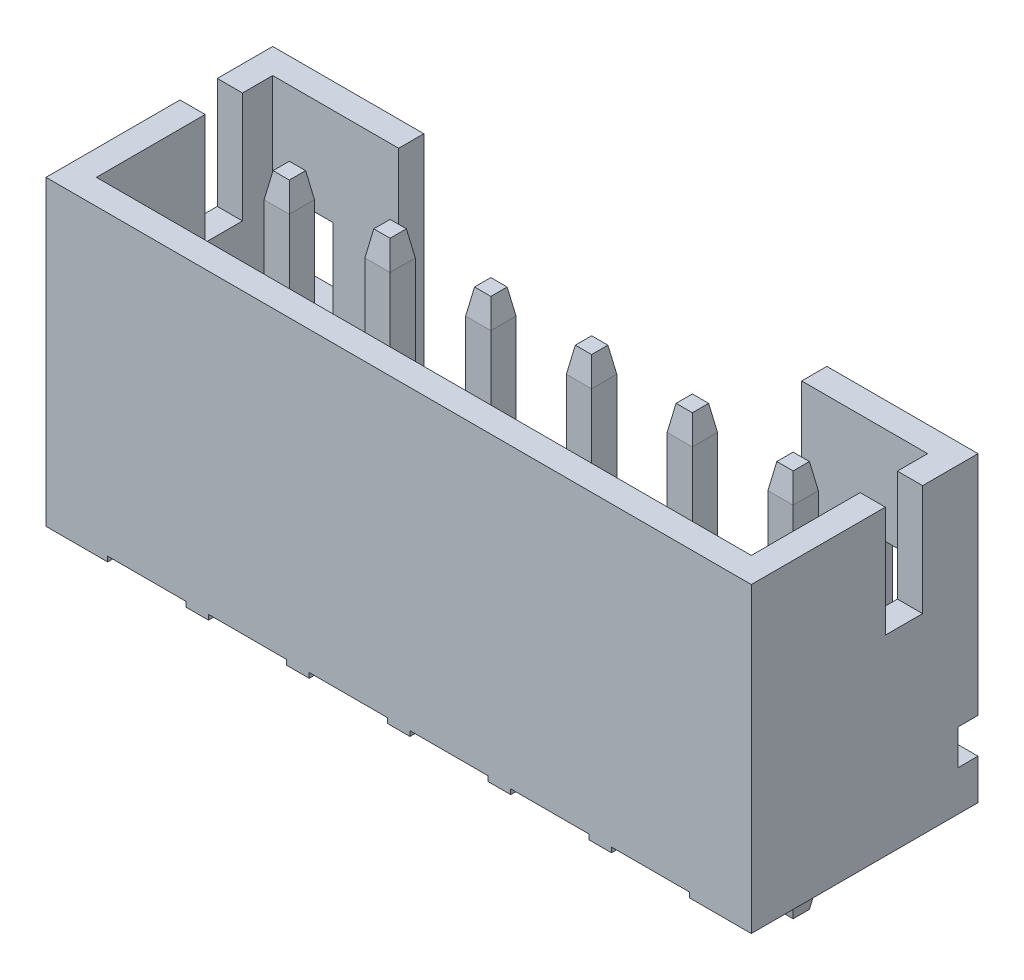
from build123d import *

# Parameters (mm, degrees)
SKETCH1_W               = 14
SKETCH1_H               = 4.5
EXTRUDE1_DEPTH          = 6
CUT_EXTRUDE1_DEPTH      = 5.5
SKETCH3_W               = 13
SKETCH3_H               = 3.5
CUT_EXTRUDE2_DEPTH      = 4.2
SKETCH5_W               = 0.74
SKETCH5_H               = 2.2
CUT_EXTRUDE3_DEPTH      = 15
SKETCH6_W               = 8
SKETCH6_H               = 4
CUT_EXTRUDE4_DEPTH      = 1.2
SKETCH9_W               = 0.4
SKETCH9_H               = 0.7
CUT_EXTRUDE5_DEPTH      = 7
CUT_EXTRUDE5_DEPTH_BACK = 9
SKETCH10_W              = 1.2
SKETCH10_H              = 1.6
CUT_EXTRUDE6_DEPTH      = 0.5
CUT_EXTRUDE7_START      = -7.5
CUT_EXTRUDE7_DEPTH      = 13
LPATTERN4_COUNT         = 3
LPATTERN4_PITCH         = 2
LPATTERN4_COL_COUNT     = 4
LPATTERN4_COL_PITCH     = 2
EXTRUDE2_START          = -2
EXTRUDE2_DEPTH          = 7.7
LPATTERN2_COUNT         = 3
LPATTERN2_PITCH         = 2
LPATTERN2_COL_COUNT     = 4
LPATTERN2_COL_PITCH     = 2
CHAMFER1_SIZE           = 0.5
CHAMFER1_SIZE2          = 0.08816349
CHAMFER1_PART_2_SIZE    = 0.5
CHAMFER1_PART_2_SIZE2   = 0.08816349
CHAMFER1_PART_3_SIZE    = 0.5
CHAMFER1_PART_3_SIZE2   = 0.08816349
CHAMFER1_PART_4_SIZE    = 0.5
CHAMFER1_PART_4_SIZE2   = 0.08816349
CHAMFER1_PART_5_SIZE    = 0.5
CHAMFER1_PART_5_SIZE2   = 0.08816349
CHAMFER1_PART_6_SIZE    = 0.5
CHAMFER1_PART_6_SIZE2   = 0.08816349
CHAMFER1_PART_7_SIZE    = 0.5
CHAMFER1_PART_7_SIZE2   = 0.08816349
CHAMFER1_PART_8_SIZE    = 0.5
CHAMFER1_PART_8_SIZE2   = 0.08816349
CHAMFER1_PART_9_SIZE    = 0.5
CHAMFER1_PART_9_SIZE2   = 0.08816349
CHAMFER1_PART_10_SIZE   = 0.5
CHAMFER1_PART_10_SIZE2  = 0.08816349
CHAMFER1_PART_11_SIZE   = 0.5
CHAMFER1_PART_11_SIZE2  = 0.08816349
CHAMFER1_PART_12_SIZE   = 0.5
CHAMFER1_PART_12_SIZE2  = 0.08816349
CHAMFER1_PART_13_SIZE   = 0.5
CHAMFER1_PART_13_SIZE2  = 0.08816349
CHAMFER1_PART_14_SIZE   = 0.5
CHAMFER1_PART_14_SIZE2  = 0.08816349
CHAMFER1_PART_15_SIZE   = 0.5
CHAMFER1_PART_15_SIZE2  = 0.08816349
CHAMFER1_PART_16_SIZE   = 0.5
CHAMFER1_PART_16_SIZE2  = 0.08816349
CHAMFER1_PART_17_SIZE   = 0.5
CHAMFER1_PART_17_SIZE2  = 0.08816349
CHAMFER1_PART_18_SIZE   = 0.5
CHAMFER1_PART_18_SIZE2  = 0.08816349
CHAMFER1_PART_19_SIZE   = 0.5
CHAMFER1_PART_19_SIZE2  = 0.08816349
CHAMFER1_PART_20_SIZE   = 0.5
CHAMFER1_PART_20_SIZE2  = 0.08816349
CHAMFER1_PART_21_SIZE   = 0.5
CHAMFER1_PART_21_SIZE2  = 0.08816349
CHAMFER1_PART_22_SIZE   = 0.5
CHAMFER1_PART_22_SIZE2  = 0.08816349
CHAMFER1_PART_23_SIZE   = 0.5
CHAMFER1_PART_23_SIZE2  = 0.08816349
CHAMFER1_PART_24_SIZE   = 0.5
CHAMFER1_PART_24_SIZE2  = 0.08816349
CHAMFER1_PART_25_SIZE   = 0.5
CHAMFER1_PART_25_SIZE2  = 0.08816349
CHAMFER1_PART_26_SIZE   = 0.5
CHAMFER1_PART_26_SIZE2  = 0.08816349
CHAMFER1_PART_27_SIZE   = 0.5
CHAMFER1_PART_27_SIZE2  = 0.08816349
CHAMFER1_PART_28_SIZE   = 0.5
CHAMFER1_PART_28_SIZE2  = 0.08816349
CHAMFER1_PART_29_SIZE   = 0.5
CHAMFER1_PART_29_SIZE2  = 0.08816349
CHAMFER1_PART_30_SIZE   = 0.5
CHAMFER1_PART_30_SIZE2  = 0.08816349
CHAMFER1_PART_31_SIZE   = 0.5
CHAMFER1_PART_31_SIZE2  = 0.08816349
CHAMFER1_PART_32_SIZE   = 0.5
CHAMFER1_PART_32_SIZE2  = 0.08816349
CHAMFER1_PART_33_SIZE   = 0.5
CHAMFER1_PART_33_SIZE2  = 0.08816349
CHAMFER1_PART_34_SIZE   = 0.5
CHAMFER1_PART_34_SIZE2  = 0.08816349
CHAMFER1_PART_35_SIZE   = 0.5
CHAMFER1_PART_35_SIZE2  = 0.08816349
CHAMFER1_PART_36_SIZE   = 0.5
CHAMFER1_PART_36_SIZE2  = 0.08816349
CHAMFER1_PART_37_SIZE   = 0.5
CHAMFER1_PART_37_SIZE2  = 0.08816349
CHAMFER1_PART_38_SIZE   = 0.5
CHAMFER1_PART_38_SIZE2  = 0.08816349
CHAMFER1_PART_39_SIZE   = 0.5
CHAMFER1_PART_39_SIZE2  = 0.08816349
CHAMFER1_PART_40_SIZE   = 0.5
CHAMFER1_PART_40_SIZE2  = 0.08816349
CHAMFER1_PART_41_SIZE   = 0.5
CHAMFER1_PART_41_SIZE2  = 0.08816349
CHAMFER1_PART_42_SIZE   = 0.5
CHAMFER1_PART_42_SIZE2  = 0.08816349
CHAMFER1_PART_43_SIZE   = 0.5
CHAMFER1_PART_43_SIZE2  = 0.08816349
CHAMFER1_PART_44_SIZE   = 0.5
CHAMFER1_PART_44_SIZE2  = 0.08816349
CHAMFER1_PART_45_SIZE   = 0.5
CHAMFER1_PART_45_SIZE2  = 0.08816349
CHAMFER1_PART_46_SIZE   = 0.5
CHAMFER1_PART_46_SIZE2  = 0.08816349
CHAMFER1_PART_47_SIZE   = 0.5
CHAMFER1_PART_47_SIZE2  = 0.08816349
CHAMFER1_PART_48_SIZE   = 0.5
CHAMFER1_PART_48_SIZE2  = 0.08816349


with BuildPart() as part:
    # Sketch1 → Extrude1 (new body)
    with BuildSketch(Plane(origin=(0, 0, 0), x_dir=(1, 0, 0), z_dir=(0, 1, 0))):
        with Locations((-1, 0)):
            Rectangle(SKETCH1_W, SKETCH1_H)
    extrude(amount=EXTRUDE1_DEPTH)

    # Sketch2 → Cut-Extrude1 (cut, through all)
    with BuildSketch(Plane.XY.offset(2.25)):
        Polygon((-0.775, 0.1), (0.775, 0.1), (0.775, 0), (0, 0), (-0.775, 0), align=None)
    cut_extrude1 = extrude(amount=-CUT_EXTRUDE1_DEPTH, mode=Mode.SUBTRACT)

    # Sketch3 → Cut-Extrude2 (cut)
    with BuildSketch(Plane(origin=(0, 6, 0), x_dir=(-1, 0, 0), z_dir=(0, 1, 0))):
        with Locations((1, 0)):
            Rectangle(SKETCH3_W, SKETCH3_H)
    extrude(amount=-CUT_EXTRUDE2_DEPTH, mode=Mode.SUBTRACT)

    # Sketch5 → Cut-Extrude3 (cut, through all)
    with BuildSketch(Plane.ZY.offset(8)):
        with Locations((-0.78, 4.9)):
            Rectangle(SKETCH5_W, SKETCH5_H)
    extrude(amount=-CUT_EXTRUDE3_DEPTH, mode=Mode.SUBTRACT)

    # Sketch6 → Cut-Extrude4 (cut)
    with BuildSketch(Plane(origin=(0, 0, -2.25), x_dir=(-1, 0, 0), z_dir=(0, 0, -1))):
        with Locations((1, 4)):
            Rectangle(SKETCH6_W, SKETCH6_H)
    extrude(amount=-CUT_EXTRUDE4_DEPTH, mode=Mode.SUBTRACT)

    # Sketch9 → Cut-Extrude5 (cut, two sides)
    with BuildSketch(Plane(origin=(0, 0, 0), x_dir=(0, 0, -1), z_dir=(1, 0, 0))) as cut_extrude5_sk:
        with Locations((2.05, 1.15)):
            Rectangle(SKETCH9_W, SKETCH9_H)
    extrude(amount=CUT_EXTRUDE5_DEPTH, mode=Mode.SUBTRACT)
    extrude(cut_extrude5_sk.sketch, amount=-CUT_EXTRUDE5_DEPTH_BACK, mode=Mode.SUBTRACT)

    # Sketch10 → Cut-Extrude6 (cut)
    with BuildSketch(Plane(origin=(0, 0, -2.25), x_dir=(-1, 0, 0), z_dir=(0, 0, -1))):
        with Locations((-4.9, 3.271645398)):
            Rectangle(SKETCH10_W, SKETCH10_H)
        with Locations((6.9, 3.271645398)):
            Rectangle(SKETCH10_W, SKETCH10_H)
    extrude(amount=-CUT_EXTRUDE6_DEPTH, mode=Mode.SUBTRACT)

    # Sketch11 → Cut-Extrude7 (cut)
    with BuildSketch(Plane(origin=(0, 0, 0), x_dir=(0, 0, -1), z_dir=(1, 0, 0)).offset(CUT_EXTRUDE7_START)):
        Polygon((0, 1.8), (-0.576387184, 1.223612816), (-1.75, 1.223612816), (-1.75, 1.8), align=None)
    extrude(amount=CUT_EXTRUDE7_DEPTH, mode=Mode.SUBTRACT)

    # LPattern4: Cut-Extrude1 ×3
    with Locations(*[(i * LPATTERN4_PITCH, 0, 0) for i in range(1, LPATTERN4_COUNT)]):
        add(cut_extrude1, mode=Mode.SUBTRACT)

    # LPattern4 col: Cut-Extrude1 ×4
    with Locations(*[(-i * LPATTERN4_COL_PITCH, 0, 0) for i in range(1, LPATTERN4_COL_COUNT)]):
        add(cut_extrude1, mode=Mode.SUBTRACT)

    # Sketch7 → Extrude2 (add)
    with BuildSketch(Plane(origin=(0, 0, 0), x_dir=(1, 0, 0), z_dir=(0, 1, 0)).offset(EXTRUDE2_START)):
        Polygon((0, 0.33), (0.25, 0.33), (0.25, 0.83), (-0.25, 0.83), (-0.25, 0.33), align=None)
    extrude2 = extrude(amount=EXTRUDE2_DEPTH)

    # LPattern2: Extrude2 ×3
    with Locations(*[(i * LPATTERN2_PITCH, 0, 0) for i in range(1, LPATTERN2_COUNT)]):
        add(extrude2)

    # LPattern2 col: Extrude2 ×4
    with Locations(*[(-i * LPATTERN2_COL_PITCH, 0, 0) for i in range(1, LPATTERN2_COL_COUNT)]):
        add(extrude2)

    # Chamfer1
    chamfer1_edges = [part.edges().sort_by_distance(p)[0] for p in [
        (-0.25, -2, -0.58),
    ]]
    chamfer1_side = [part.faces().sort_by_distance(p)[0] for p in [
        (-0.25, -0.95, -0.58),
    ]]
    chamfer(chamfer1_edges, length=CHAMFER1_SIZE, length2=CHAMFER1_SIZE2, reference=chamfer1_side[0])

    # Chamfer1 part 2
    chamfer1_part_2_edges = [part.edges().sort_by_distance(p)[0] for p in [
        (0, -2, -0.33),
    ]]
    chamfer1_part_2_side = [part.faces().sort_by_distance(p)[0] for p in [
        (0, -0.95, -0.33),
    ]]
    chamfer(chamfer1_part_2_edges, length=CHAMFER1_PART_2_SIZE, length2=CHAMFER1_PART_2_SIZE2, reference=chamfer1_part_2_side[0])

    # Chamfer1 part 3
    chamfer1_part_3_edges = [part.edges().sort_by_distance(p)[0] for p in [
        (0.25, -2, -0.58),
    ]]
    chamfer1_part_3_side = [part.faces().sort_by_distance(p)[0] for p in [
        (0.25, -0.95, -0.58),
    ]]
    chamfer(chamfer1_part_3_edges, length=CHAMFER1_PART_3_SIZE, length2=CHAMFER1_PART_3_SIZE2, reference=chamfer1_part_3_side[0])

    # Chamfer1 part 4
    chamfer1_part_4_edges = [part.edges().sort_by_distance(p)[0] for p in [
        (0, -2, -0.83),
    ]]
    chamfer1_part_4_side = [part.faces().sort_by_distance(p)[0] for p in [
        (0, -0.95, -0.83),
    ]]
    chamfer(chamfer1_part_4_edges, length=CHAMFER1_PART_4_SIZE, length2=CHAMFER1_PART_4_SIZE2, reference=chamfer1_part_4_side[0])

    # Chamfer1 part 5
    chamfer1_part_5_edges = [part.edges().sort_by_distance(p)[0] for p in [
        (0, 5.7, -0.83),
    ]]
    chamfer1_part_5_side = [part.faces().sort_by_distance(p)[0] for p in [
        (0, 3.75, -0.83),
    ]]
    chamfer(chamfer1_part_5_edges, length=CHAMFER1_PART_5_SIZE, length2=CHAMFER1_PART_5_SIZE2, reference=chamfer1_part_5_side[0])

    # Chamfer1 part 6
    chamfer1_part_6_edges = [part.edges().sort_by_distance(p)[0] for p in [
        (-0.25, 5.7, -0.58),
    ]]
    chamfer1_part_6_side = [part.faces().sort_by_distance(p)[0] for p in [
        (-0.25, 3.75, -0.58),
    ]]
    chamfer(chamfer1_part_6_edges, length=CHAMFER1_PART_6_SIZE, length2=CHAMFER1_PART_6_SIZE2, reference=chamfer1_part_6_side[0])

    # Chamfer1 part 7
    chamfer1_part_7_edges = [part.edges().sort_by_distance(p)[0] for p in [
        (0, 5.7, -0.33),
    ]]
    chamfer1_part_7_side = [part.faces().sort_by_distance(p)[0] for p in [
        (0, 3.75, -0.33),
    ]]
    chamfer(chamfer1_part_7_edges, length=CHAMFER1_PART_7_SIZE, length2=CHAMFER1_PART_7_SIZE2, reference=chamfer1_part_7_side[0])

    # Chamfer1 part 8
    chamfer1_part_8_edges = [part.edges().sort_by_distance(p)[0] for p in [
        (0.25, 5.7, -0.58),
    ]]
    chamfer1_part_8_side = [part.faces().sort_by_distance(p)[0] for p in [
        (0.25, 3.75, -0.58),
    ]]
    chamfer(chamfer1_part_8_edges, length=CHAMFER1_PART_8_SIZE, length2=CHAMFER1_PART_8_SIZE2, reference=chamfer1_part_8_side[0])

    # Chamfer1 part 9
    chamfer1_part_9_edges = [part.edges().sort_by_distance(p)[0] for p in [
        (-2.25, -2, -0.58),
    ]]
    chamfer1_part_9_side = [part.faces().sort_by_distance(p)[0] for p in [
        (-2.25, -0.95, -0.58),
    ]]
    chamfer(chamfer1_part_9_edges, length=CHAMFER1_PART_9_SIZE, length2=CHAMFER1_PART_9_SIZE2, reference=chamfer1_part_9_side[0])

    # Chamfer1 part 10
    chamfer1_part_10_edges = [part.edges().sort_by_distance(p)[0] for p in [
        (-2, -2, -0.33),
    ]]
    chamfer1_part_10_side = [part.faces().sort_by_distance(p)[0] for p in [
        (-2, -0.95, -0.33),
    ]]
    chamfer(chamfer1_part_10_edges, length=CHAMFER1_PART_10_SIZE, length2=CHAMFER1_PART_10_SIZE2, reference=chamfer1_part_10_side[0])

    # Chamfer1 part 11
    chamfer1_part_11_edges = [part.edges().sort_by_distance(p)[0] for p in [
        (-1.75, -2, -0.58),
    ]]
    chamfer1_part_11_side = [part.faces().sort_by_distance(p)[0] for p in [
        (-1.75, -0.95, -0.58),
    ]]
    chamfer(chamfer1_part_11_edges, length=CHAMFER1_PART_11_SIZE, length2=CHAMFER1_PART_11_SIZE2, reference=chamfer1_part_11_side[0])

    # Chamfer1 part 12
    chamfer1_part_12_edges = [part.edges().sort_by_distance(p)[0] for p in [
        (-2, -2, -0.83),
    ]]
    chamfer1_part_12_side = [part.faces().sort_by_distance(p)[0] for p in [
        (-2, -0.95, -0.83),
    ]]
    chamfer(chamfer1_part_12_edges, length=CHAMFER1_PART_12_SIZE, length2=CHAMFER1_PART_12_SIZE2, reference=chamfer1_part_12_side[0])

    # Chamfer1 part 13
    chamfer1_part_13_edges = [part.edges().sort_by_distance(p)[0] for p in [
        (-2, 5.7, -0.83),
    ]]
    chamfer1_part_13_side = [part.faces().sort_by_distance(p)[0] for p in [
        (-2, 3.75, -0.83),
    ]]
    chamfer(chamfer1_part_13_edges, length=CHAMFER1_PART_13_SIZE, length2=CHAMFER1_PART_13_SIZE2, reference=chamfer1_part_13_side[0])

    # Chamfer1 part 14
    chamfer1_part_14_edges = [part.edges().sort_by_distance(p)[0] for p in [
        (-2.25, 5.7, -0.58),
    ]]
    chamfer1_part_14_side = [part.faces().sort_by_distance(p)[0] for p in [
        (-2.25, 3.75, -0.58),
    ]]
    chamfer(chamfer1_part_14_edges, length=CHAMFER1_PART_14_SIZE, length2=CHAMFER1_PART_14_SIZE2, reference=chamfer1_part_14_side[0])

    # Chamfer1 part 15
    chamfer1_part_15_edges = [part.edges().sort_by_distance(p)[0] for p in [
        (-2, 5.7, -0.33),
    ]]
    chamfer1_part_15_side = [part.faces().sort_by_distance(p)[0] for p in [
        (-2, 3.75, -0.33),
    ]]
    chamfer(chamfer1_part_15_edges, length=CHAMFER1_PART_15_SIZE, length2=CHAMFER1_PART_15_SIZE2, reference=chamfer1_part_15_side[0])

    # Chamfer1 part 16
    chamfer1_part_16_edges = [part.edges().sort_by_distance(p)[0] for p in [
        (-1.75, 5.7, -0.58),
    ]]
    chamfer1_part_16_side = [part.faces().sort_by_distance(p)[0] for p in [
        (-1.75, 3.75, -0.58),
    ]]
    chamfer(chamfer1_part_16_edges, length=CHAMFER1_PART_16_SIZE, length2=CHAMFER1_PART_16_SIZE2, reference=chamfer1_part_16_side[0])

    # Chamfer1 part 17
    chamfer1_part_17_edges = [part.edges().sort_by_distance(p)[0] for p in [
        (-4.25, -2, -0.58),
    ]]
    chamfer1_part_17_side = [part.faces().sort_by_distance(p)[0] for p in [
        (-4.25, -0.95, -0.58),
    ]]
    chamfer(chamfer1_part_17_edges, length=CHAMFER1_PART_17_SIZE, length2=CHAMFER1_PART_17_SIZE2, reference=chamfer1_part_17_side[0])

    # Chamfer1 part 18
    chamfer1_part_18_edges = [part.edges().sort_by_distance(p)[0] for p in [
        (-4, -2, -0.33),
    ]]
    chamfer1_part_18_side = [part.faces().sort_by_distance(p)[0] for p in [
        (-4, -0.95, -0.33),
    ]]
    chamfer(chamfer1_part_18_edges, length=CHAMFER1_PART_18_SIZE, length2=CHAMFER1_PART_18_SIZE2, reference=chamfer1_part_18_side[0])

    # Chamfer1 part 19
    chamfer1_part_19_edges = [part.edges().sort_by_distance(p)[0] for p in [
        (-3.75, -2, -0.58),
    ]]
    chamfer1_part_19_side = [part.faces().sort_by_distance(p)[0] for p in [
        (-3.75, -0.95, -0.58),
    ]]
    chamfer(chamfer1_part_19_edges, length=CHAMFER1_PART_19_SIZE, length2=CHAMFER1_PART_19_SIZE2, reference=chamfer1_part_19_side[0])

    # Chamfer1 part 20
    chamfer1_part_20_edges = [part.edges().sort_by_distance(p)[0] for p in [
        (-4, -2, -0.83),
    ]]
    chamfer1_part_20_side = [part.faces().sort_by_distance(p)[0] for p in [
        (-4, -0.95, -0.83),
    ]]
    chamfer(chamfer1_part_20_edges, length=CHAMFER1_PART_20_SIZE, length2=CHAMFER1_PART_20_SIZE2, reference=chamfer1_part_20_side[0])

    # Chamfer1 part 21
    chamfer1_part_21_edges = [part.edges().sort_by_distance(p)[0] for p in [
        (-4, 5.7, -0.83),
    ]]
    chamfer1_part_21_side = [part.faces().sort_by_distance(p)[0] for p in [
        (-4, 3.75, -0.83),
    ]]
    chamfer(chamfer1_part_21_edges, length=CHAMFER1_PART_21_SIZE, length2=CHAMFER1_PART_21_SIZE2, reference=chamfer1_part_21_side[0])

    # Chamfer1 part 22
    chamfer1_part_22_edges = [part.edges().sort_by_distance(p)[0] for p in [
        (-4.25, 5.7, -0.58),
    ]]
    chamfer1_part_22_side = [part.faces().sort_by_distance(p)[0] for p in [
        (-4.25, 3.75, -0.58),
    ]]
    chamfer(chamfer1_part_22_edges, length=CHAMFER1_PART_22_SIZE, length2=CHAMFER1_PART_22_SIZE2, reference=chamfer1_part_22_side[0])

    # Chamfer1 part 23
    chamfer1_part_23_edges = [part.edges().sort_by_distance(p)[0] for p in [
        (-4, 5.7, -0.33),
    ]]
    chamfer1_part_23_side = [part.faces().sort_by_distance(p)[0] for p in [
        (-4, 3.75, -0.33),
    ]]
    chamfer(chamfer1_part_23_edges, length=CHAMFER1_PART_23_SIZE, length2=CHAMFER1_PART_23_SIZE2, reference=chamfer1_part_23_side[0])

    # Chamfer1 part 24
    chamfer1_part_24_edges = [part.edges().sort_by_distance(p)[0] for p in [
        (-3.75, 5.7, -0.58),
    ]]
    chamfer1_part_24_side = [part.faces().sort_by_distance(p)[0] for p in [
        (-3.75, 3.75, -0.58),
    ]]
    chamfer(chamfer1_part_24_edges, length=CHAMFER1_PART_24_SIZE, length2=CHAMFER1_PART_24_SIZE2, reference=chamfer1_part_24_side[0])

    # Chamfer1 part 25
    chamfer1_part_25_edges = [part.edges().sort_by_distance(p)[0] for p in [
        (-6.25, -2, -0.58),
    ]]
    chamfer1_part_25_side = [part.faces().sort_by_distance(p)[0] for p in [
        (-6.25, -0.95, -0.58),
    ]]
    chamfer(chamfer1_part_25_edges, length=CHAMFER1_PART_25_SIZE, length2=CHAMFER1_PART_25_SIZE2, reference=chamfer1_part_25_side[0])

    # Chamfer1 part 26
    chamfer1_part_26_edges = [part.edges().sort_by_distance(p)[0] for p in [
        (-6, -2, -0.33),
    ]]
    chamfer1_part_26_side = [part.faces().sort_by_distance(p)[0] for p in [
        (-6, -0.95, -0.33),
    ]]
    chamfer(chamfer1_part_26_edges, length=CHAMFER1_PART_26_SIZE, length2=CHAMFER1_PART_26_SIZE2, reference=chamfer1_part_26_side[0])

    # Chamfer1 part 27
    chamfer1_part_27_edges = [part.edges().sort_by_distance(p)[0] for p in [
        (-5.75, -2, -0.58),
    ]]
    chamfer1_part_27_side = [part.faces().sort_by_distance(p)[0] for p in [
        (-5.75, -0.95, -0.58),
    ]]
    chamfer(chamfer1_part_27_edges, length=CHAMFER1_PART_27_SIZE, length2=CHAMFER1_PART_27_SIZE2, reference=chamfer1_part_27_side[0])

    # Chamfer1 part 28
    chamfer1_part_28_edges = [part.edges().sort_by_distance(p)[0] for p in [
        (-6, -2, -0.83),
    ]]
    chamfer1_part_28_side = [part.faces().sort_by_distance(p)[0] for p in [
        (-6, -0.95, -0.83),
    ]]
    chamfer(chamfer1_part_28_edges, length=CHAMFER1_PART_28_SIZE, length2=CHAMFER1_PART_28_SIZE2, reference=chamfer1_part_28_side[0])

    # Chamfer1 part 29
    chamfer1_part_29_edges = [part.edges().sort_by_distance(p)[0] for p in [
        (-6, 5.7, -0.83),
    ]]
    chamfer1_part_29_side = [part.faces().sort_by_distance(p)[0] for p in [
        (-6, 3.75, -0.83),
    ]]
    chamfer(chamfer1_part_29_edges, length=CHAMFER1_PART_29_SIZE, length2=CHAMFER1_PART_29_SIZE2, reference=chamfer1_part_29_side[0])

    # Chamfer1 part 30
    chamfer1_part_30_edges = [part.edges().sort_by_distance(p)[0] for p in [
        (-6.25, 5.7, -0.58),
    ]]
    chamfer1_part_30_side = [part.faces().sort_by_distance(p)[0] for p in [
        (-6.25, 3.75, -0.58),
    ]]
    chamfer(chamfer1_part_30_edges, length=CHAMFER1_PART_30_SIZE, length2=CHAMFER1_PART_30_SIZE2, reference=chamfer1_part_30_side[0])

    # Chamfer1 part 31
    chamfer1_part_31_edges = [part.edges().sort_by_distance(p)[0] for p in [
        (-6, 5.7, -0.33),
    ]]
    chamfer1_part_31_side = [part.faces().sort_by_distance(p)[0] for p in [
        (-6, 3.75, -0.33),
    ]]
    chamfer(chamfer1_part_31_edges, length=CHAMFER1_PART_31_SIZE, length2=CHAMFER1_PART_31_SIZE2, reference=chamfer1_part_31_side[0])

    # Chamfer1 part 32
    chamfer1_part_32_edges = [part.edges().sort_by_distance(p)[0] for p in [
        (-5.75, 5.7, -0.58),
    ]]
    chamfer1_part_32_side = [part.faces().sort_by_distance(p)[0] for p in [
        (-5.75, 3.75, -0.58),
    ]]
    chamfer(chamfer1_part_32_edges, length=CHAMFER1_PART_32_SIZE, length2=CHAMFER1_PART_32_SIZE2, reference=chamfer1_part_32_side[0])

    # Chamfer1 part 33
    chamfer1_part_33_edges = [part.edges().sort_by_distance(p)[0] for p in [
        (1.75, -2, -0.58),
    ]]
    chamfer1_part_33_side = [part.faces().sort_by_distance(p)[0] for p in [
        (1.75, -0.95, -0.58),
    ]]
    chamfer(chamfer1_part_33_edges, length=CHAMFER1_PART_33_SIZE, length2=CHAMFER1_PART_33_SIZE2, reference=chamfer1_part_33_side[0])

    # Chamfer1 part 34
    chamfer1_part_34_edges = [part.edges().sort_by_distance(p)[0] for p in [
        (2, -2, -0.33),
    ]]
    chamfer1_part_34_side = [part.faces().sort_by_distance(p)[0] for p in [
        (2, -0.95, -0.33),
    ]]
    chamfer(chamfer1_part_34_edges, length=CHAMFER1_PART_34_SIZE, length2=CHAMFER1_PART_34_SIZE2, reference=chamfer1_part_34_side[0])

    # Chamfer1 part 35
    chamfer1_part_35_edges = [part.edges().sort_by_distance(p)[0] for p in [
        (2.25, -2, -0.58),
    ]]
    chamfer1_part_35_side = [part.faces().sort_by_distance(p)[0] for p in [
        (2.25, -0.95, -0.58),
    ]]
    chamfer(chamfer1_part_35_edges, length=CHAMFER1_PART_35_SIZE, length2=CHAMFER1_PART_35_SIZE2, reference=chamfer1_part_35_side[0])

    # Chamfer1 part 36
    chamfer1_part_36_edges = [part.edges().sort_by_distance(p)[0] for p in [
        (2, -2, -0.83),
    ]]
    chamfer1_part_36_side = [part.faces().sort_by_distance(p)[0] for p in [
        (2, -0.95, -0.83),
    ]]
    chamfer(chamfer1_part_36_edges, length=CHAMFER1_PART_36_SIZE, length2=CHAMFER1_PART_36_SIZE2, reference=chamfer1_part_36_side[0])

    # Chamfer1 part 37
    chamfer1_part_37_edges = [part.edges().sort_by_distance(p)[0] for p in [
        (2, 5.7, -0.83),
    ]]
    chamfer1_part_37_side = [part.faces().sort_by_distance(p)[0] for p in [
        (2, 3.75, -0.83),
    ]]
    chamfer(chamfer1_part_37_edges, length=CHAMFER1_PART_37_SIZE, length2=CHAMFER1_PART_37_SIZE2, reference=chamfer1_part_37_side[0])

    # Chamfer1 part 38
    chamfer1_part_38_edges = [part.edges().sort_by_distance(p)[0] for p in [
        (1.75, 5.7, -0.58),
    ]]
    chamfer1_part_38_side = [part.faces().sort_by_distance(p)[0] for p in [
        (1.75, 3.75, -0.58),
    ]]
    chamfer(chamfer1_part_38_edges, length=CHAMFER1_PART_38_SIZE, length2=CHAMFER1_PART_38_SIZE2, reference=chamfer1_part_38_side[0])

    # Chamfer1 part 39
    chamfer1_part_39_edges = [part.edges().sort_by_distance(p)[0] for p in [
        (2, 5.7, -0.33),
    ]]
    chamfer1_part_39_side = [part.faces().sort_by_distance(p)[0] for p in [
        (2, 3.75, -0.33),
    ]]
    chamfer(chamfer1_part_39_edges, length=CHAMFER1_PART_39_SIZE, length2=CHAMFER1_PART_39_SIZE2, reference=chamfer1_part_39_side[0])

    # Chamfer1 part 40
    chamfer1_part_40_edges = [part.edges().sort_by_distance(p)[0] for p in [
        (2.25, 5.7, -0.58),
    ]]
    chamfer1_part_40_side = [part.faces().sort_by_distance(p)[0] for p in [
        (2.25, 3.75, -0.58),
    ]]
    chamfer(chamfer1_part_40_edges, length=CHAMFER1_PART_40_SIZE, length2=CHAMFER1_PART_40_SIZE2, reference=chamfer1_part_40_side[0])

    # Chamfer1 part 41
    chamfer1_part_41_edges = [part.edges().sort_by_distance(p)[0] for p in [
        (3.75, -2, -0.58),
    ]]
    chamfer1_part_41_side = [part.faces().sort_by_distance(p)[0] for p in [
        (3.75, -0.95, -0.58),
    ]]
    chamfer(chamfer1_part_41_edges, length=CHAMFER1_PART_41_SIZE, length2=CHAMFER1_PART_41_SIZE2, reference=chamfer1_part_41_side[0])

    # Chamfer1 part 42
    chamfer1_part_42_edges = [part.edges().sort_by_distance(p)[0] for p in [
        (4, -2, -0.33),
    ]]
    chamfer1_part_42_side = [part.faces().sort_by_distance(p)[0] for p in [
        (4, -0.95, -0.33),
    ]]
    chamfer(chamfer1_part_42_edges, length=CHAMFER1_PART_42_SIZE, length2=CHAMFER1_PART_42_SIZE2, reference=chamfer1_part_42_side[0])

    # Chamfer1 part 43
    chamfer1_part_43_edges = [part.edges().sort_by_distance(p)[0] for p in [
        (4.25, -2, -0.58),
    ]]
    chamfer1_part_43_side = [part.faces().sort_by_distance(p)[0] for p in [
        (4.25, -0.95, -0.58),
    ]]
    chamfer(chamfer1_part_43_edges, length=CHAMFER1_PART_43_SIZE, length2=CHAMFER1_PART_43_SIZE2, reference=chamfer1_part_43_side[0])

    # Chamfer1 part 44
    chamfer1_part_44_edges = [part.edges().sort_by_distance(p)[0] for p in [
        (4, -2, -0.83),
    ]]
    chamfer1_part_44_side = [part.faces().sort_by_distance(p)[0] for p in [
        (4, -0.95, -0.83),
    ]]
    chamfer(chamfer1_part_44_edges, length=CHAMFER1_PART_44_SIZE, length2=CHAMFER1_PART_44_SIZE2, reference=chamfer1_part_44_side[0])

    # Chamfer1 part 45
    chamfer1_part_45_edges = [part.edges().sort_by_distance(p)[0] for p in [
        (4, 5.7, -0.83),
    ]]
    chamfer1_part_45_side = [part.faces().sort_by_distance(p)[0] for p in [
        (4, 3.75, -0.83),
    ]]
    chamfer(chamfer1_part_45_edges, length=CHAMFER1_PART_45_SIZE, length2=CHAMFER1_PART_45_SIZE2, reference=chamfer1_part_45_side[0])

    # Chamfer1 part 46
    chamfer1_part_46_edges = [part.edges().sort_by_distance(p)[0] for p in [
        (3.75, 5.7, -0.58),
    ]]
    chamfer1_part_46_side = [part.faces().sort_by_distance(p)[0] for p in [
        (3.75, 3.75, -0.58),
    ]]
    chamfer(chamfer1_part_46_edges, length=CHAMFER1_PART_46_SIZE, length2=CHAMFER1_PART_46_SIZE2, reference=chamfer1_part_46_side[0])

    # Chamfer1 part 47
    chamfer1_part_47_edges = [part.edges().sort_by_distance(p)[0] for p in [
        (4, 5.7, -0.33),
    ]]
    chamfer1_part_47_side = [part.faces().sort_by_distance(p)[0] for p in [
        (4, 3.75, -0.33),
    ]]
    chamfer(chamfer1_part_47_edges, length=CHAMFER1_PART_47_SIZE, length2=CHAMFER1_PART_47_SIZE2, reference=chamfer1_part_47_side[0])

    # Chamfer1 part 48
    chamfer1_part_48_edges = [part.edges().sort_by_distance(p)[0] for p in [
        (4.25, 5.7, -0.58),
    ]]
    chamfer1_part_48_side = [part.faces().sort_by_distance(p)[0] for p in [
        (4.25, 3.75, -0.58),
    ]]
    chamfer(chamfer1_part_48_edges, length=CHAMFER1_PART_48_SIZE, length2=CHAMFER1_PART_48_SIZE2, reference=chamfer1_part_48_side[0])


solid = part.part
